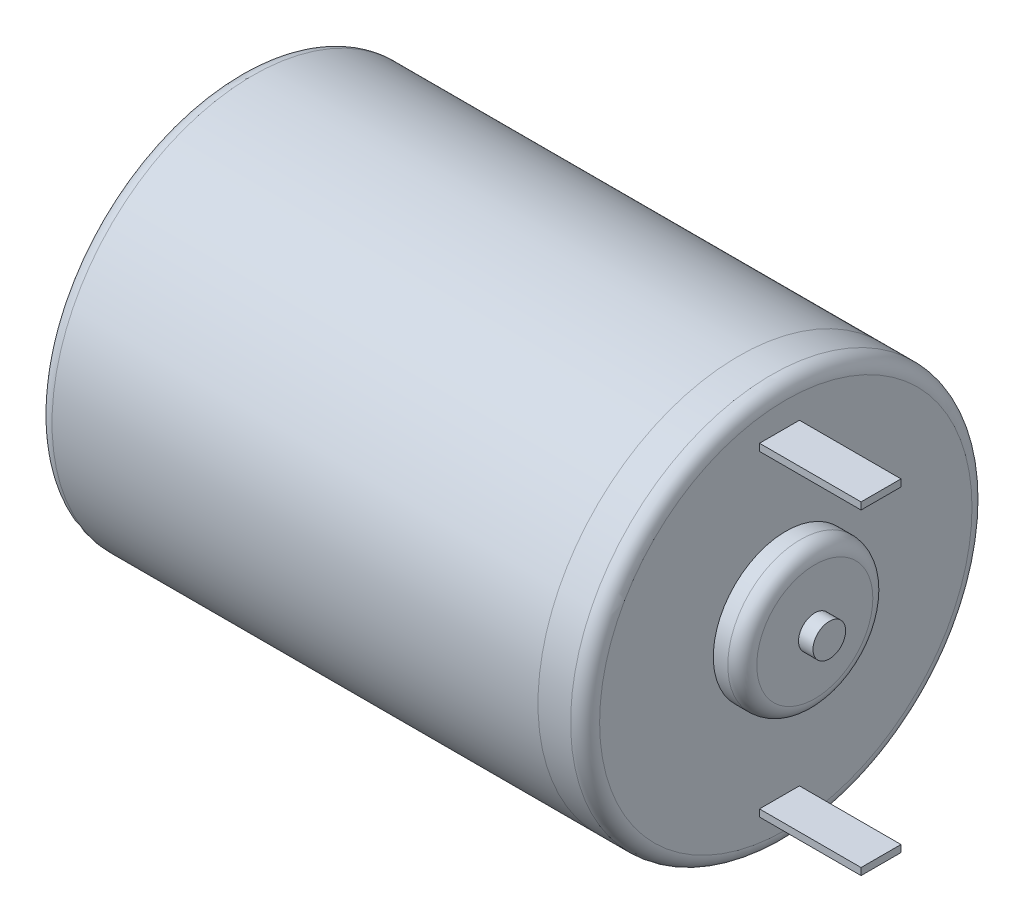
from build123d import *

# Parameters (mm, degrees)
SKETCH1_R           = 13.835
BOSS_EXTRUDE1_DEPTH = 34.5
SKETCH2_R           = 13.835
BOSS_EXTRUDE2_DEPTH = 3.25
SKETCH3_R           = 5
BOSS_EXTRUDE3_DEPTH = 2
FILLET1_R           = 1
SKETCH4_R           = 1.125
BOSS_EXTRUDE4_DEPTH = 1
FILLET2_R           = 1
SKETCH5_W           = 2.75
SKETCH5_H           = 0.485466573
BOSS_EXTRUDE5_DEPTH = 7


with BuildPart() as part:
    # Sketch1 → Boss-Extrude1 (new body)
    with BuildSketch(Plane(origin=(0, 0, 0), x_dir=(0, 0, -1), z_dir=(1, 0, 0))):
        Circle(SKETCH1_R)
    extrude(amount=BOSS_EXTRUDE1_DEPTH)

    # Fillet1
    fillet1_edges = [part.edges().sort_by_distance(p)[0] for p in [
        (0, 0, 13.835),
    ]]
    fillet(fillet1_edges, radius=FILLET1_R)


with BuildPart() as body_2:
    # Sketch2 → Boss-Extrude2 (new body)
    with BuildSketch(Plane(origin=(34.5, 0, 0), x_dir=(0, 0, -1), z_dir=(1, 0, 0))):
        Circle(SKETCH2_R)
    extrude(amount=BOSS_EXTRUDE2_DEPTH)

    # Sketch3 → Boss-Extrude3 (add)
    with BuildSketch(Plane(origin=(37.75, 0, 0), x_dir=(0, 0, -1), z_dir=(1, 0, 0))):
        Circle(SKETCH3_R)
    extrude(amount=BOSS_EXTRUDE3_DEPTH)

    # Sketch4 → Boss-Extrude4 (add)
    with BuildSketch(Plane(origin=(39.75, 0, 0), x_dir=(0, 0, -1), z_dir=(1, 0, 0))):
        Circle(SKETCH4_R)
    extrude(amount=BOSS_EXTRUDE4_DEPTH)

    # Fillet2
    fillet2_edges = [body_2.edges().sort_by_distance(p)[0] for p in [
        (37.75, 0, 13.835),
        (39.75, 0, 5),
    ]]
    fillet(fillet2_edges, radius=FILLET2_R)

    # Sketch5 → Boss-Extrude5 (add)
    with BuildSketch(Plane(origin=(37.75, 0, 0), x_dir=(0, 0, -1), z_dir=(1, 0, 0))):
        with Locations((-0.43656989, -10.914149911)):
            Rectangle(SKETCH5_W, SKETCH5_H)
    boss_extrude5 = extrude(amount=BOSS_EXTRUDE5_DEPTH)

    # Mirror1: Boss-Extrude5 across plane
    add(boss_extrude5.mirror(Plane.ZX))


solid = Compound([part.part, body_2.part])
